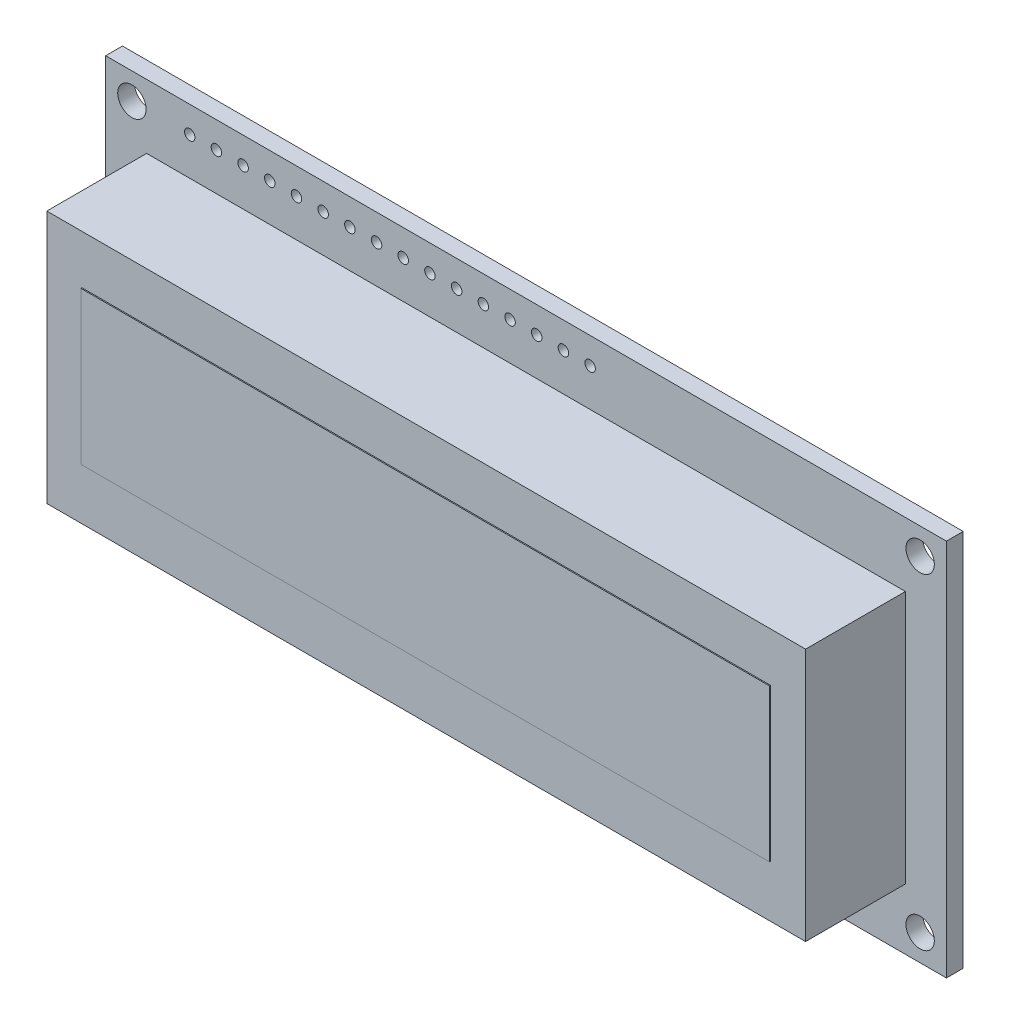
from build123d import *

# Parameters (mm, degrees)
ESBO_O1_W                = 80
ESBO_O1_H                = 36
ESBO_O1_R                = 1.35
RESSALTO_EXTRUS_O1_DEPTH = 1.6
ESBO_O4_W                = 65.5
ESBO_O4_H                = 14.5
RESSALTO_EXTRUS_O2_DEPTH = 9.6
ESBO_O3_W                = 72.2
ESBO_O3_H                = 24.1
RESSALTO_EXTRUS_O3_DEPTH = 9.5
ESBO_O5_R                = 0.5
CORTE_EXTRUS_O1_DEPTH    = 2.6


with BuildPart() as part:
    # Esboço1 → Ressalto-extrusão1 (new body)
    with BuildSketch(Plane.XY):
        with Locations((40, 18)):
            Rectangle(ESBO_O1_W, ESBO_O1_H)
        with Locations((2.5, 33.5)):
            Circle(ESBO_O1_R, mode=Mode.SUBTRACT)
        with Locations((2.5, 2.5)):
            Circle(ESBO_O1_R, mode=Mode.SUBTRACT)
        with Locations((77.5, 33.5)):
            Circle(ESBO_O1_R, mode=Mode.SUBTRACT)
        with Locations((77.5, 2.5)):
            Circle(ESBO_O1_R, mode=Mode.SUBTRACT)
    extrude(amount=RESSALTO_EXTRUS_O1_DEPTH)

    # Esboço4 → Ressalto-extrusão2 (add)
    with BuildSketch(Plane.XY.offset(1.6)):
        with Locations((40, 18)):
            Rectangle(ESBO_O4_W, ESBO_O4_H)
    extrude(amount=RESSALTO_EXTRUS_O2_DEPTH)

    # Esboço3 → Ressalto-extrusão3 (add)
    with BuildSketch(Plane.XY.offset(1.6)):
        with Locations((40, 17.85)):
            Rectangle(ESBO_O3_W, ESBO_O3_H)
    extrude(amount=RESSALTO_EXTRUS_O3_DEPTH)

    # Esboço5 → Corte-extrusão1 (cut, through all)
    with BuildSketch(Plane.XY.offset(1.6)):
        with Locations((8, 33.5)):
            Circle(ESBO_O5_R)
        with Locations((10.54, 33.5)):
            Circle(ESBO_O5_R)
        with Locations((13.08, 33.5)):
            Circle(ESBO_O5_R)
        with Locations((15.62, 33.5)):
            Circle(ESBO_O5_R)
        with Locations((18.16, 33.5)):
            Circle(ESBO_O5_R)
        with Locations((20.7, 33.5)):
            Circle(ESBO_O5_R)
        with Locations((23.24, 33.5)):
            Circle(ESBO_O5_R)
        with Locations((25.78, 33.5)):
            Circle(ESBO_O5_R)
        with Locations((28.32, 33.5)):
            Circle(ESBO_O5_R)
        with Locations((30.86, 33.5)):
            Circle(ESBO_O5_R)
        with Locations((33.4, 33.5)):
            Circle(ESBO_O5_R)
        with Locations((35.94, 33.5)):
            Circle(ESBO_O5_R)
        with Locations((38.48, 33.5)):
            Circle(ESBO_O5_R)
        with Locations((41.02, 33.5)):
            Circle(ESBO_O5_R)
        with Locations((43.56, 33.5)):
            Circle(ESBO_O5_R)
        with Locations((46.1, 33.5)):
            Circle(ESBO_O5_R)
    extrude(amount=-CORTE_EXTRUS_O1_DEPTH, mode=Mode.SUBTRACT)


solid = part.part
